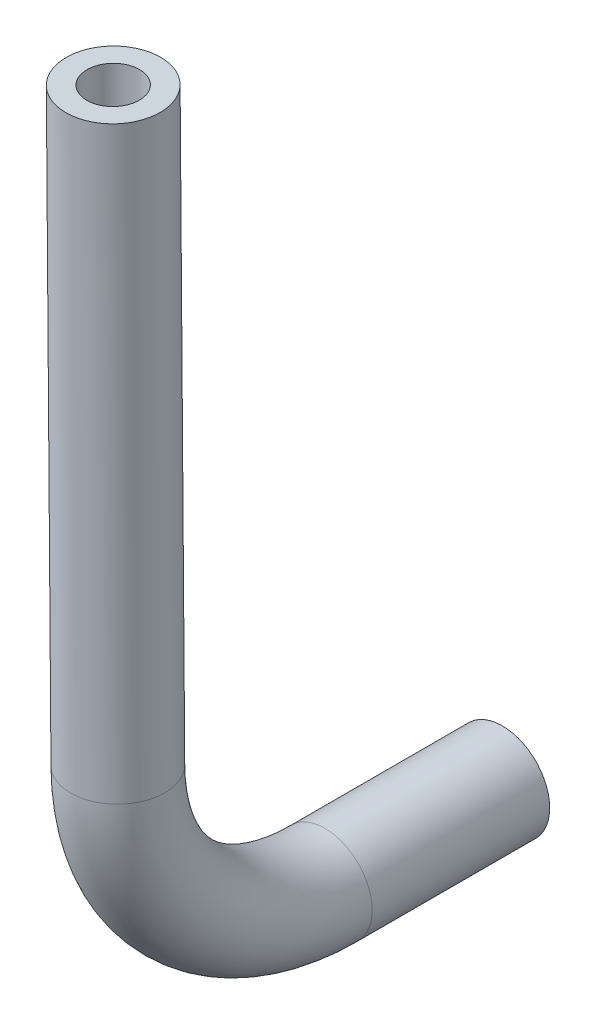
from build123d import *

# Parameters (mm, degrees)
SKETCH1_R           = 1.6
SKETCH1_R_2         = 0.89
SKETCH1_2_R         = 1.6
SKETCH1_2_R_2       = 0.89
BOSS_EXTRUDE1_DEPTH = 6
SKETCH5_R           = 1.6
SKETCH5_R_2         = 0.89
BOSS_EXTRUDE2_DEPTH = 20


with BuildPart() as part:
    # Sweep1: sweep along a path in Sketch2
    with BuildLine(Plane(origin=(0, 0, 0), x_dir=(0, 0, -1), z_dir=(1, 0, 0))) as sweep1_path:
        ThreePointArc((0, 0), (-4.930222368, 2.030804149), (-6.99978301, 6.944883598))
    # Sketch1 → Sweep1 (sweep)
    with BuildSketch(Plane.XY):
        Circle(SKETCH1_R)
        Circle(SKETCH1_R_2, mode=Mode.SUBTRACT)
    sweep(path=sweep1_path.line)

    # Sketch1_2 → Boss-Extrude1 (add)
    with BuildSketch(Plane.XY):
        Circle(SKETCH1_2_R)
        Circle(SKETCH1_2_R_2, mode=Mode.SUBTRACT)
    extrude(amount=-BOSS_EXTRUDE1_DEPTH)

    # Sketch5 → Boss-Extrude2 (add)
    with BuildSketch(Plane(origin=(0, 6.999566026, 0.055114693), x_dir=(1, 0, 0), z_dir=(0, 0.9999690013794313, 0.007873771664404696))):
        with Locations((0, -6.944883598)):
            Circle(SKETCH5_R)
        with Locations((0, -6.944883598)):
            Circle(SKETCH5_R_2, mode=Mode.SUBTRACT)
    extrude(amount=BOSS_EXTRUDE2_DEPTH)


solid = part.part
